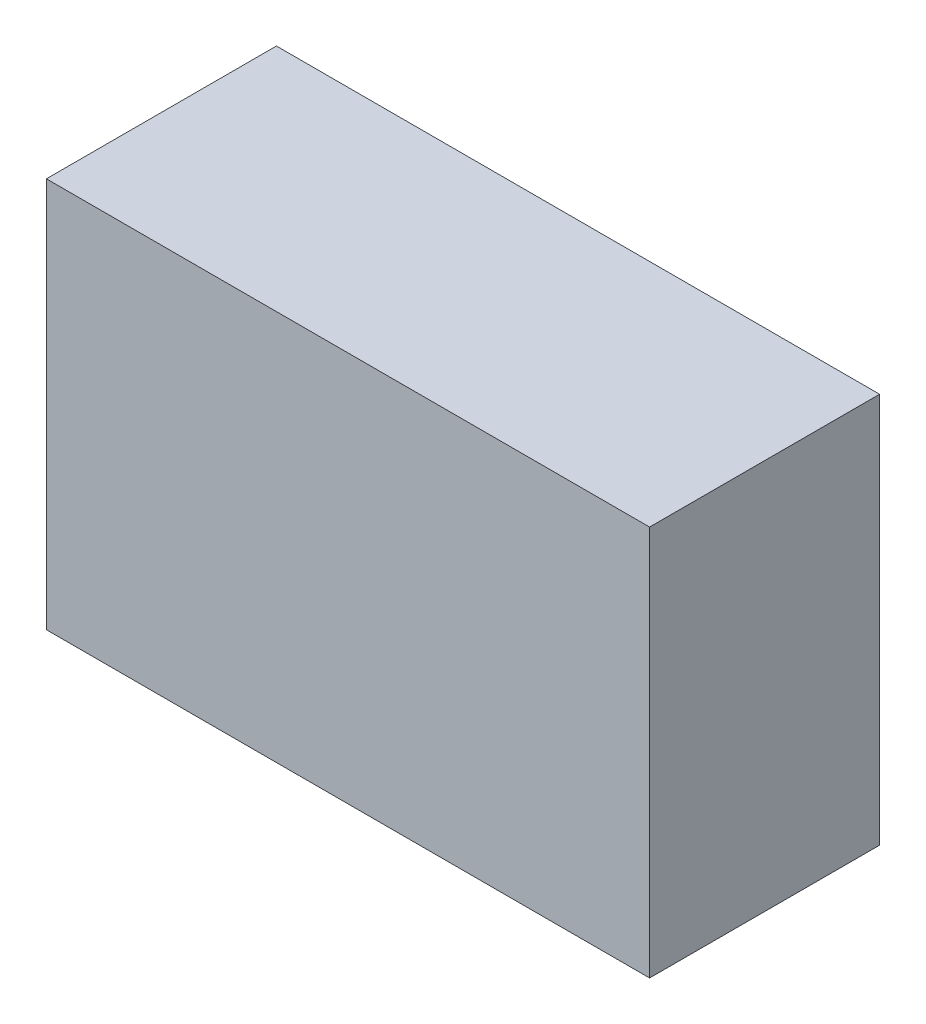
from build123d import *

# Parameters (mm, degrees)
SKETCH1_W           = 118
SKETCH1_H           = 76.4
BOSS_EXTRUDE1_DEPTH = 45


with BuildPart() as part:
    # Sketch1 → Boss-Extrude1 (new body)
    with BuildSketch(Plane.XY):
        with Locations((-15.839536929, 25.073117764)):
            Rectangle(SKETCH1_W, SKETCH1_H)
    extrude(amount=-BOSS_EXTRUDE1_DEPTH)


solid = part.part
